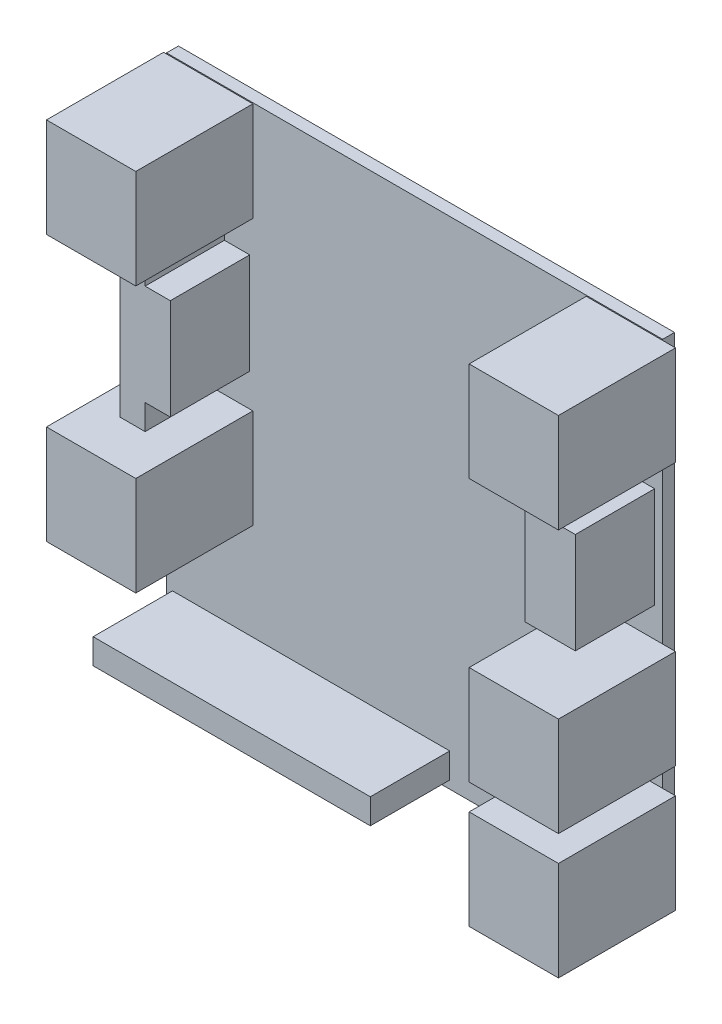
from build123d import *

# Parameters (mm, degrees)
CROQUIS1_W              = 50
CROQUIS1_H              = 50
SALIENTE_EXTRUIR1_DEPTH = 1.2
CROQUIS2_W              = 9
CROQUIS2_H              = 10
SALIENTE_EXTRUIR2_DEPTH = 11.8
CROQUIS3_W              = 27.94
CROQUIS3_H              = 2.54
CROQUIS3_W_2            = 2.54
CROQUIS3_H_2            = 15.24
CROQUIS3_H_3            = 10.16
CROQUIS3_W_3            = 5.08
SALIENTE_EXTRUIR3_DEPTH = 8


with BuildPart() as part:
    # Croquis1 → Saliente-Extruir1 (new body)
    with BuildSketch(Plane.XY):
        with Locations((25, 25)):
            Rectangle(CROQUIS1_W, CROQUIS1_H)
    extrude(amount=SALIENTE_EXTRUIR1_DEPTH)

    # Croquis2 → Saliente-Extruir2 (add)
    with BuildSketch(Plane.XY.offset(1.2)):
        with Locations((46.8, 5.8)):
            Rectangle(CROQUIS2_W, CROQUIS2_H)
        with Locations((46.8, 18.4)):
            Rectangle(CROQUIS2_W, CROQUIS2_H)
        with Locations((46.8, 44.9)):
            Rectangle(CROQUIS2_W, CROQUIS2_H)
        with Locations((4.2, 44.9)):
            Rectangle(CROQUIS2_W, CROQUIS2_H)
        with Locations((4.2, 18.1)):
            Rectangle(CROQUIS2_W, CROQUIS2_H)
    extrude(amount=SALIENTE_EXTRUIR2_DEPTH)

    # Croquis3 → Saliente-Extruir3 (add)
    with BuildSketch(Plane.XY.offset(1.2)):
        with Locations((14.57, 2.07)):
            Rectangle(CROQUIS3_W, CROQUIS3_H)
        with Locations((4.57, 31.48)):
            Rectangle(CROQUIS3_W_2, CROQUIS3_H_2)
        with Locations((7.11, 31.48)):
            Rectangle(CROQUIS3_W_2, CROQUIS3_H_3)
        with Locations((46.66, 31.48)):
            Rectangle(CROQUIS3_W_3, CROQUIS3_H_3)
    extrude(amount=SALIENTE_EXTRUIR3_DEPTH)


solid = part.part
